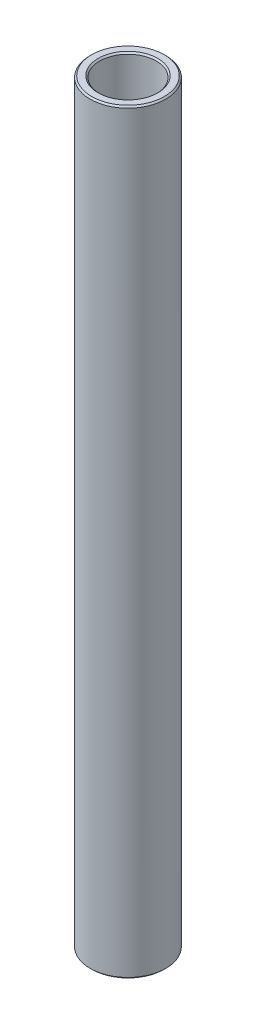
from build123d import *

# Parameters (mm, degrees)
SKETCH1_W     = 1.5875
SKETCH1_H     = 127
CHAMFER1_SIZE = 0.254


with BuildPart() as part:
    # Sketch1 → Revolve1 (revolve)
    with BuildSketch(Plane.XY):
        with Locations((5.55625, 0)):
            Rectangle(SKETCH1_W, SKETCH1_H)
    revolve(axis=Axis((0, 11.60859375, 0), (0, -1, 0)))

    # Chamfer1
    chamfer1_edges = [part.edges().sort_by_distance(p)[0] for p in [
        (-4.7625, -63.5, 0),
        (-6.35, -63.5, 0),
        (-6.35, 63.5, 0),
        (-4.7625, 63.5, 0),
    ]]
    chamfer(chamfer1_edges, length=CHAMFER1_SIZE)


solid = part.part
